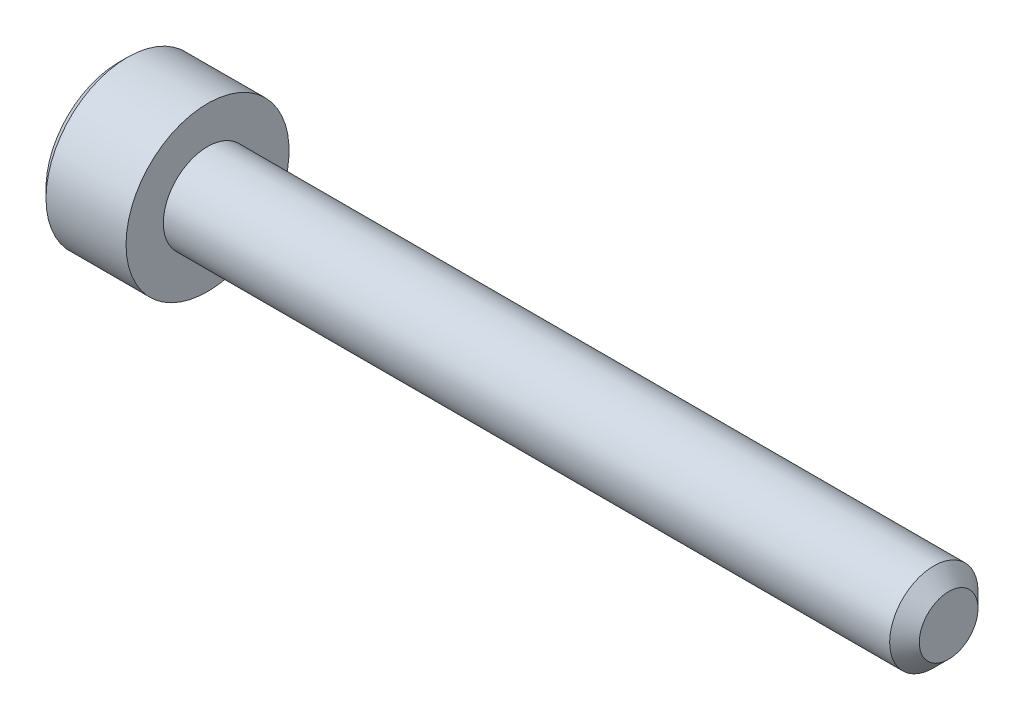
from build123d import *

# Parameters (mm, degrees)
CHAMFER1_SIZE      = 0.5
CHAMFER2_SIZE      = 0.3
CUT_EXTRUDE1_DEPTH = 2.5
CHAMFER3_SIZE      = 0.3


with BuildPart() as part:
    # Sketch1 → Revolve1 (revolve)
    with BuildSketch(Plane.XY):
        Polygon((0, 0), (0, 2.75), (3, 2.75), (3, 1.49), (28, 1.49), (28, 0), align=None)
    revolve(axis=Axis((-88.705490849, 0, 0), (1, 0, 0)))

    # Chamfer1
    chamfer1_edges = [part.edges().sort_by_distance(p)[0] for p in [
        (28, -1.49, 0),
    ]]
    chamfer(chamfer1_edges, length=CHAMFER1_SIZE)

    # Chamfer2
    chamfer2_edges = [part.edges().sort_by_distance(p)[0] for p in [
        (0, -2.75, 0),
    ]]
    chamfer(chamfer2_edges, length=CHAMFER2_SIZE)

    # Sketch3 → Cut-Extrude1 (cut)
    with BuildSketch(Plane(origin=(0, 0, 0), x_dir=(0, 0, -1), z_dir=(1, 0, 0))):
        Polygon((-1.443375673, 0), (-0.721687836, -1.25), (0.721687836, -1.25), (1.443375673, 0), (0.721687836, 1.25), (-0.721687836, 1.25), align=None)
    extrude(amount=CUT_EXTRUDE1_DEPTH, mode=Mode.SUBTRACT)

    # Chamfer3
    chamfer3_edges = [part.edges().sort_by_distance(p)[0] for p in [
        (0, 1.25, 0),
        (0, 0.625, 1.082531755),
        (0, -0.625, 1.082531755),
        (0, -1.25, 0),
        (0, -0.625, -1.082531755),
        (0, 0.625, -1.082531755),
    ]]
    chamfer(chamfer3_edges, length=CHAMFER3_SIZE)


solid = part.part
